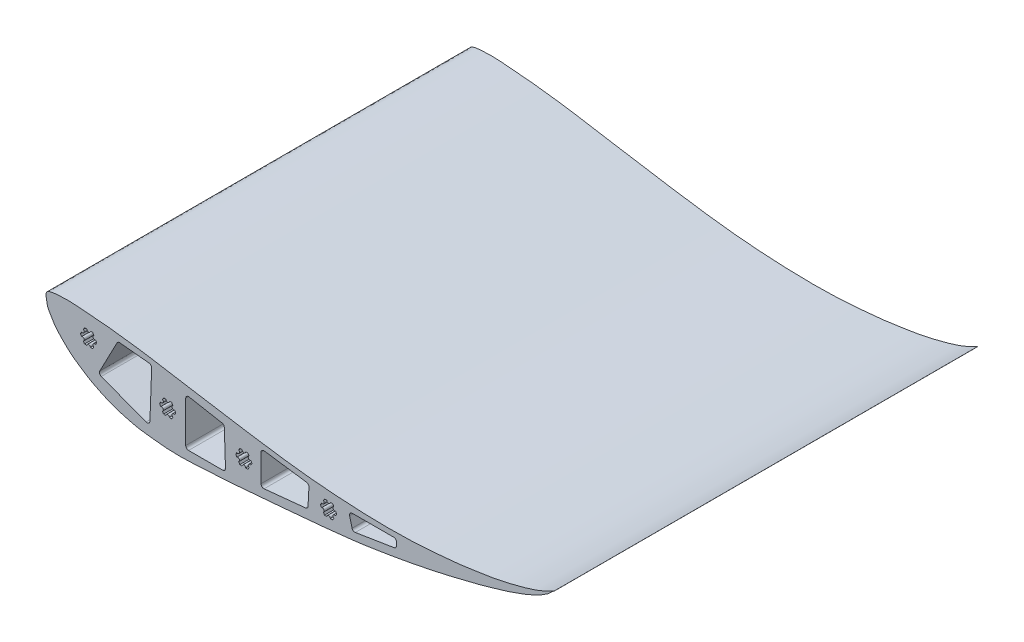
from build123d import *

# Parameters (mm, degrees)
BOSS_EXTRUDE1_DEPTH = 381
CUT_EXTRUDE3_DEPTH  = 381


with BuildPart() as part:
    # Sketch1 → Boss-Extrude1 (new body)
    with BuildSketch(Plane.XY):
        with BuildLine():
            add(Edge.make_bspline(
                [(-16.622525288, 91.56967272), (-16.794942994, 92.772317911), (-17.515788121, 97.582670832), (-2.852582554, 99.497127174), (9.154054709, 99.213304724), (23.433217875, 97.797752429), (34.6859051, 97.019819773), (46.592767258, 95.707761604), (58.472171701, 94.254609297), (72.666253463, 92.219697635), (88.15460255, 89.685431784), (109.15740223, 86.162485471), (130.076144789, 82.711728928), (150.055716296, 79.576696099), (168.256858053, 76.617688262), (186.559493812, 73.857794613), (206.695059336, 71.20791695), (225.195546149, 69.114961125), (244.068606399, 67.656695297), (262.594452449, 66.476567979), (282.222526995, 65.926744761), (300.99609332, 65.813021246), (318.737894065, 66.539084176), (334.742865336, 67.61277327), (348.252438633, 69.009944705), (359.067906447, 70.049570339), (367.896874578, 71.420704301), (377.007425502, 72.883057797), (386.227823421, 74.138373924), (395.367743176, 76.385575861), (403.564697097, 77.907582397), (410.735250399, 79.953005658), (417.114285798, 81.687412008), (422.732680223, 83.591992804), (427.164087313, 85.094079009), (431.171696898, 86.937153076), (434.607250511, 88.392786361), (443.123217376, 93.275688905), (437.255094337, 89.117703468), (435.279778464, 86.561175616), (431.573501891, 84.704524529), (428.464842726, 82.201032813), (424.134266462, 80.398696308), (419.425258521, 77.797857577), (414.105440345, 75.713007702), (408.77839072, 73.798734141), (403.684867312, 72.029145889), (396.961540144, 69.466067962), (387.343622202, 67.136732033), (376.830663922, 63.608926675), (365.24798357, 60.901656463), (354.754672426, 58.255886458), (344.650791699, 55.720154361), (336.670341174, 53.941801639), (329.235250959, 52.381752299), (321.327868225, 50.676833739), (310.892392252, 48.725728026), (298.426712372, 46.308387166), (284.136528131, 44.189578856), (268.909448728, 41.574011521), (251.075314715, 39.596728872), (229.386892765, 37.203012777), (203.753382466, 34.933554815), (177.46976253, 32.720447696), (150.443659112, 30.344574846), (123.02307167, 28.688327838), (101.004781565, 27.555963663), (84.804305156, 28.931500406), (75.72348416, 30.010523718), (67.270753352, 30.977463397), (60.250592801, 32.582425676), (53.932519662, 34.232006507), (47.114759922, 36.133551764), (41.43120503, 38.368275103), (36.428795002, 40.445297648), (32.069577899, 42.402430324), (27.662403595, 44.667790264), (23.104788958, 46.965799851), (18.73168781, 49.734821084), (12.723675127, 53.669846892), (5.809434759, 58.404883079), (-1.037305312, 65.077409289), (-6.513200759, 70.614178991), (-10.540658158, 76.008047875), (-12.880350205, 80.406543609), (-15.167480815, 84.128221175), (-16.123087236, 87.961419413), (-16.453570873, 90.391184614), (-16.622525288, 91.56967272)],
                knots=[0, 0, 0, 0, 0.003644297, 0.013581344, 0.034074787, 0.047557163, 0.057150579, 0.06958931, 0.084962672, 0.094623108, 0.114452008, 0.134073068, 0.161263036, 0.180794832, 0.197357561, 0.218965716, 0.238711125, 0.26090768, 0.277214827, 0.297940316, 0.318988728, 0.338651177, 0.356673355, 0.374539934, 0.388835783, 0.399172974, 0.408530924, 0.416784345, 0.428053881, 0.437617365, 0.446213781, 0.454125754, 0.460928052, 0.466918155, 0.472615005, 0.475771621, 0.480179638, 0.487250343, 0.490988881, 0.49507496, 0.498775568, 0.503369536, 0.507624299, 0.513322415, 0.520215853, 0.525455504, 0.531043662, 0.537088919, 0.5479516, 0.561953721, 0.571760074, 0.585151118, 0.595822817, 0.604354359, 0.61073386, 0.619595652, 0.629664863, 0.643953388, 0.659323518, 0.674864947, 0.692287919, 0.715453133, 0.743149301, 0.772805526, 0.797998576, 0.828023399, 0.858832685, 0.866768477, 0.87886578, 0.88746214, 0.893357873, 0.901377327, 0.907903322, 0.915486693, 0.920464298, 0.924856032, 0.930432876, 0.935970498, 0.940815755, 0.946613865, 0.958462559, 0.966932993, 0.97647901, 0.982815006, 0.98789669, 0.992067686, 0.996428904, 1, 1, 1, 1], degree=3))
        make_face()
    extrude(amount=BOSS_EXTRUDE1_DEPTH)

    # Sketch4 → Cut-Extrude3 (cut)
    with BuildSketch(Plane.XY.offset(381)):
        with BuildLine():
            Line((88.931300118, 66.243537573), (91.009974327, 66.243537573))
            ThreePointArc((91.009974327, 66.243537573), (92.597474327, 64.656037573), (94.184974327, 66.243537573))
            Line((94.184974327, 66.243537573), (96.263648536, 66.243537573))
            Line((96.263648536, 66.243537573), (97.302985641, 64.443352902))
            ThreePointArc((97.302985641, 64.443352902), (96.721920503, 62.274787243), (98.890486301, 61.693722626))
            Line((98.890486301, 61.693722626), (99.929823515, 59.893537766))
            Line((99.929823515, 59.893537766), (98.89048641, 58.093353094))
            ThreePointArc((98.89048641, 58.093353094), (96.721921082, 57.512287766), (97.30298641, 55.343722437))
            Line((97.30298641, 55.343722437), (96.263649306, 53.543537766))
            Line((96.263649306, 53.543537766), (94.184975096, 53.543537766))
            ThreePointArc((94.184975096, 53.543537766), (92.597475, 55.131037573), (91.009975096, 53.543537573))
            Line((91.009975096, 53.543537573), (88.931300887, 53.543537573))
            Line((88.931300887, 53.543537573), (87.891963673, 55.343722182))
            ThreePointArc((87.891963673, 55.343722182), (88.47302887, 57.512287545), (86.304463507, 58.093352743))
            Line((86.304463507, 58.093352743), (85.265126293, 59.893537351))
            Line((85.265126293, 59.893537351), (86.304463288, 61.693722086))
            ThreePointArc((86.304463288, 61.693722086), (88.473028582, 62.274787545), (87.891963122, 64.443352839))
            Line((87.891963122, 64.443352839), (88.931300118, 66.243537573))
        make_face()
        with BuildLine():
            Line((17.811300118, 85.293537573), (19.889974327, 85.293537573))
            ThreePointArc((19.889974327, 85.293537573), (21.477474327, 83.706037573), (23.064974327, 85.293537573))
            Line((23.064974327, 85.293537573), (25.143648536, 85.293537573))
            Line((25.143648536, 85.293537573), (26.182985641, 83.493352902))
            ThreePointArc((26.182985641, 83.493352902), (25.601920503, 81.324787243), (27.770486301, 80.743722626))
            Line((27.770486301, 80.743722626), (28.809823515, 78.943537766))
            Line((28.809823515, 78.943537766), (27.77048641, 77.143353094))
            ThreePointArc((27.77048641, 77.143353094), (25.601921082, 76.562287766), (26.18298641, 74.393722437))
            Line((26.18298641, 74.393722437), (25.143649306, 72.593537766))
            Line((25.143649306, 72.593537766), (23.064975096, 72.593537766))
            ThreePointArc((23.064975096, 72.593537766), (21.477475, 74.181037573), (19.889975096, 72.593537573))
            Line((19.889975096, 72.593537573), (17.811300887, 72.593537573))
            Line((17.811300887, 72.593537573), (16.771963673, 74.393722182))
            ThreePointArc((16.771963673, 74.393722182), (17.35302887, 76.562287545), (15.184463507, 77.143352743))
            Line((15.184463507, 77.143352743), (14.145126293, 78.943537351))
            Line((14.145126293, 78.943537351), (15.184463288, 80.743722086))
            ThreePointArc((15.184463288, 80.743722086), (17.353028582, 81.324787545), (16.771963122, 83.493352839))
            Line((16.771963122, 83.493352839), (17.811300118, 85.293537573))
        make_face()
        with BuildLine():
            Line((233.711300118, 59.893537573), (235.789974327, 59.893537573))
            ThreePointArc((235.789974327, 59.893537573), (237.377474327, 58.306037573), (238.964974327, 59.893537573))
            Line((238.964974327, 59.893537573), (241.043648536, 59.893537573))
            Line((241.043648536, 59.893537573), (242.082985641, 58.093352902))
            ThreePointArc((242.082985641, 58.093352902), (241.501920503, 55.924787243), (243.670486301, 55.343722626))
            Line((243.670486301, 55.343722626), (244.709823515, 53.543537766))
            Line((244.709823515, 53.543537766), (243.67048641, 51.743353094))
            ThreePointArc((243.67048641, 51.743353094), (241.501921082, 51.162287766), (242.08298641, 48.993722437))
            Line((242.08298641, 48.993722437), (241.043649306, 47.193537766))
            Line((241.043649306, 47.193537766), (238.964975096, 47.193537766))
            ThreePointArc((238.964975096, 47.193537766), (237.377475, 48.781037573), (235.789975096, 47.193537573))
            Line((235.789975096, 47.193537573), (233.711300887, 47.193537573))
            Line((233.711300887, 47.193537573), (232.671963673, 48.993722182))
            ThreePointArc((232.671963673, 48.993722182), (233.25302887, 51.162287545), (231.084463507, 51.743352743))
            Line((231.084463507, 51.743352743), (230.045126293, 53.543537351))
            Line((230.045126293, 53.543537351), (231.084463288, 55.343722086))
            ThreePointArc((231.084463288, 55.343722086), (233.253028582, 55.924787545), (232.671963122, 58.093352839))
            Line((232.671963122, 58.093352839), (233.711300118, 59.893537573))
        make_face()
        with BuildLine():
            Line((157.511300118, 61.163537573), (159.589974327, 61.163537573))
            ThreePointArc((159.589974327, 61.163537573), (161.177474327, 59.576037573), (162.764974327, 61.163537573))
            Line((162.764974327, 61.163537573), (164.843648536, 61.163537573))
            Line((164.843648536, 61.163537573), (165.882985641, 59.363352902))
            ThreePointArc((165.882985641, 59.363352902), (165.301920503, 57.194787243), (167.470486301, 56.613722626))
            Line((167.470486301, 56.613722626), (168.509823515, 54.813537766))
            Line((168.509823515, 54.813537766), (167.47048641, 53.013353094))
            ThreePointArc((167.47048641, 53.013353094), (165.301921082, 52.432287766), (165.88298641, 50.263722437))
            Line((165.88298641, 50.263722437), (164.843649306, 48.463537766))
            Line((164.843649306, 48.463537766), (162.764975096, 48.463537766))
            ThreePointArc((162.764975096, 48.463537766), (161.177475, 50.051037573), (159.589975096, 48.463537573))
            Line((159.589975096, 48.463537573), (157.511300887, 48.463537573))
            Line((157.511300887, 48.463537573), (156.471963673, 50.263722182))
            ThreePointArc((156.471963673, 50.263722182), (157.05302887, 52.432287545), (154.884463507, 53.013352743))
            Line((154.884463507, 53.013352743), (153.845126293, 54.813537351))
            Line((153.845126293, 54.813537351), (154.884463288, 56.613722086))
            ThreePointArc((154.884463288, 56.613722086), (157.053028582, 57.194787545), (156.471963122, 59.363352839))
            Line((156.471963122, 59.363352839), (157.511300118, 61.163537573))
        make_face()
        with BuildLine():
            Line((31.501207482, 58.37669779), (47.032113751, 88.081016492))
            ThreePointArc((47.032113751, 88.081016492), (48.076445172, 89.139261035), (49.534182489, 89.431684603))
            Line((49.534182489, 89.431684603), (75.93058222, 86.808602351))
            ThreePointArc((75.93058222, 86.808602351), (77.593752589, 85.950453195), (78.217633108, 84.185990458))
            Line((78.217633108, 84.185990458), (76.631821885, 41.843273018))
            ThreePointArc((76.631821885, 41.843273018), (75.497981954, 39.821894696), (73.194863199, 39.56265096))
            Line((73.194863199, 39.56265096), (32.853368422, 54.824131949))
            ThreePointArc((32.853368422, 54.824131949), (31.378241648, 56.296285615), (31.501207482, 58.37669779))
        make_face()
        with BuildLine():
            Line((111.858309541, 78.393902518), (141.485442222, 72.962296795))
            ThreePointArc((141.485442222, 72.962296795), (142.950940478, 72.12274223), (143.565962065, 70.549756072))
            Line((143.565962065, 70.549756072), (144.628770085, 39.112135773))
            ThreePointArc((144.628770085, 39.112135773), (143.916361615, 37.260866924), (142.090220332, 36.486315313))
            Line((142.090220332, 36.486315313), (111.400279631, 36.486315313))
            ThreePointArc((111.400279631, 36.486315313), (109.604228407, 37.230264089), (108.860279631, 39.026315313))
            Line((108.860279631, 39.026315313), (108.860279631, 75.895541334))
            ThreePointArc((108.860279631, 75.895541334), (109.774210132, 77.846822448), (111.858309541, 78.393902518))
        make_face()
        with BuildLine():
            Line((179.473393864, 70.165192722), (217.50482476, 64.769576264))
            ThreePointArc((217.50482476, 64.769576264), (219.108331349, 63.86995645), (219.68467301, 62.123995546))
            Line((219.68467301, 62.123995546), (218.890378913, 46.71578744))
            ThreePointArc((218.890378913, 46.71578744), (218.192789678, 45.094545708), (216.607247121, 44.319232678))
            Line((216.607247121, 44.319232678), (179.370110323, 40.58420072))
            ThreePointArc((179.370110323, 40.58420072), (177.412540188, 41.227973149), (176.576610312, 43.111519011))
            Line((176.576610312, 43.111519011), (176.576610312, 67.650375533))
            ThreePointArc((176.576610312, 67.650375533), (177.451472213, 69.568425352), (179.473393864, 70.165192722))
        make_face()
        with BuildLine():
            Line((258.751236774, 61.163537573), (296.003687002, 61.163537573))
            ThreePointArc((296.003687002, 61.163537573), (297.799738226, 60.419588797), (298.543687002, 58.623537573))
            Line((298.543687002, 58.623537573), (298.543687002, 55.707363059))
            ThreePointArc((298.543687002, 55.707363059), (297.937199117, 54.060204626), (296.407363457, 53.199645906))
            Line((296.407363457, 53.199645906), (261.377375447, 47.560739881))
            ThreePointArc((261.377375447, 47.560739881), (259.584877656, 47.941775277), (258.515299797, 49.429807368))
            Line((258.515299797, 49.429807368), (256.292837579, 57.984887907))
            ThreePointArc((256.292837579, 57.984887907), (256.742036666, 60.177472876), (258.751236774, 61.163537573))
        make_face()
    extrude(amount=-CUT_EXTRUDE3_DEPTH, mode=Mode.SUBTRACT)


solid = part.part
